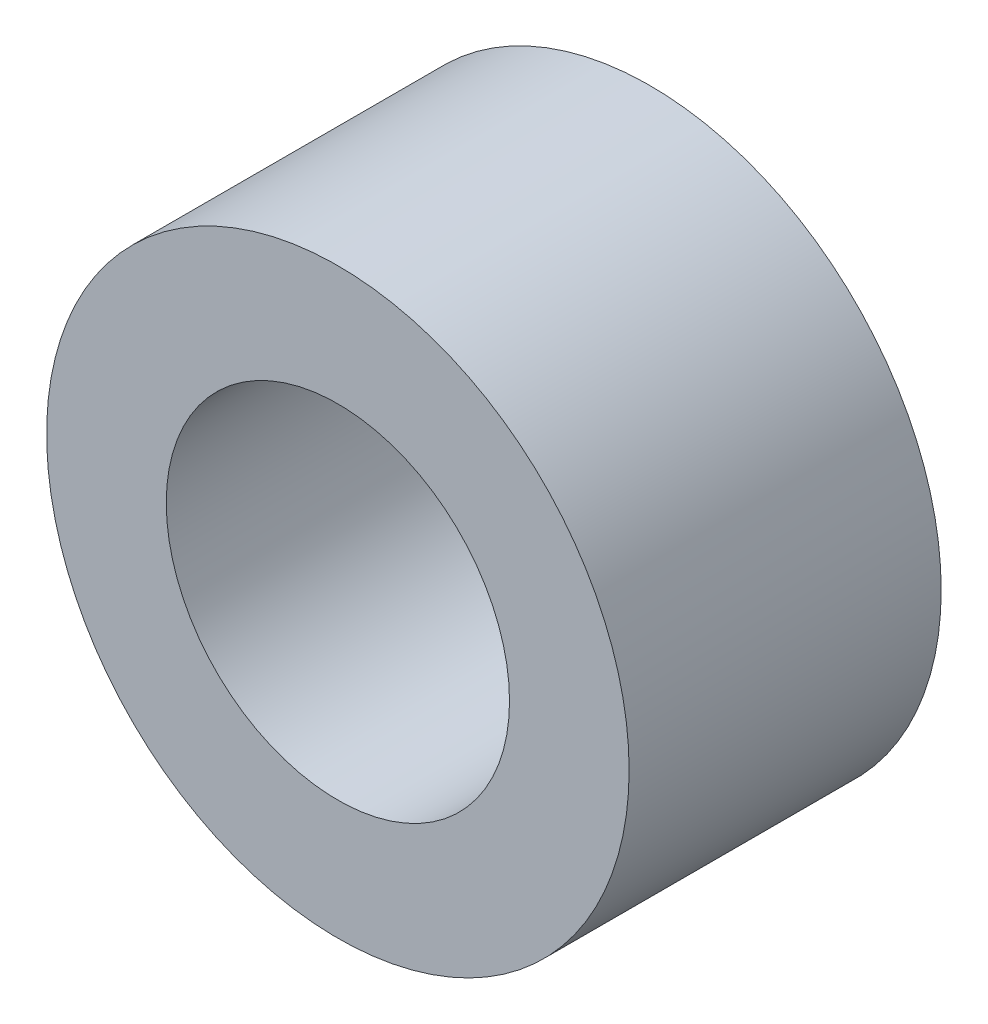
from build123d import *

# Parameters (mm, degrees)
SKETCH_1_R      = 2.8
SKETCH_1_R_2    = 1.65
EXTRUDE_1_DEPTH = 3


with BuildPart() as part:
    # 草图1 → 凸台-拉伸1 (new body)
    with BuildSketch(Plane.XY):
        Circle(SKETCH_1_R)
        Circle(SKETCH_1_R_2, mode=Mode.SUBTRACT)
    extrude(amount=EXTRUDE_1_DEPTH)


solid = part.part
